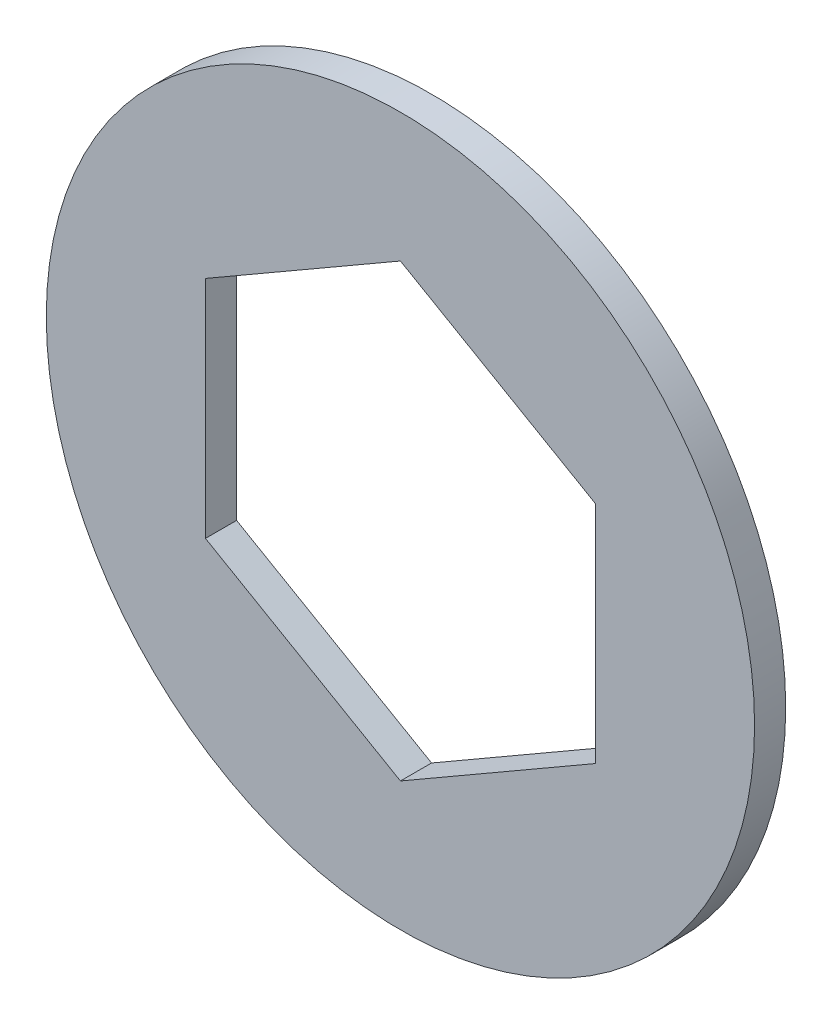
from build123d import *

# Parameters (mm, degrees)
ESQUISSE1_R        = 45.5
BOSS_EXTRU_1_DEPTH = 4


with BuildPart() as part:
    # Esquisse1 → Boss.-Extru.1 (new body)
    with BuildSketch(Plane.XY):
        Circle(ESQUISSE1_R)
        Polygon((0, 28.925248486), (-25.05, 14.462624243), (-25.05, -14.462624243), (0, -28.925248486), (25.05, -14.462624243), (25.05, 14.462624243), align=None, mode=Mode.SUBTRACT)
    extrude(amount=BOSS_EXTRU_1_DEPTH)


solid = part.part
